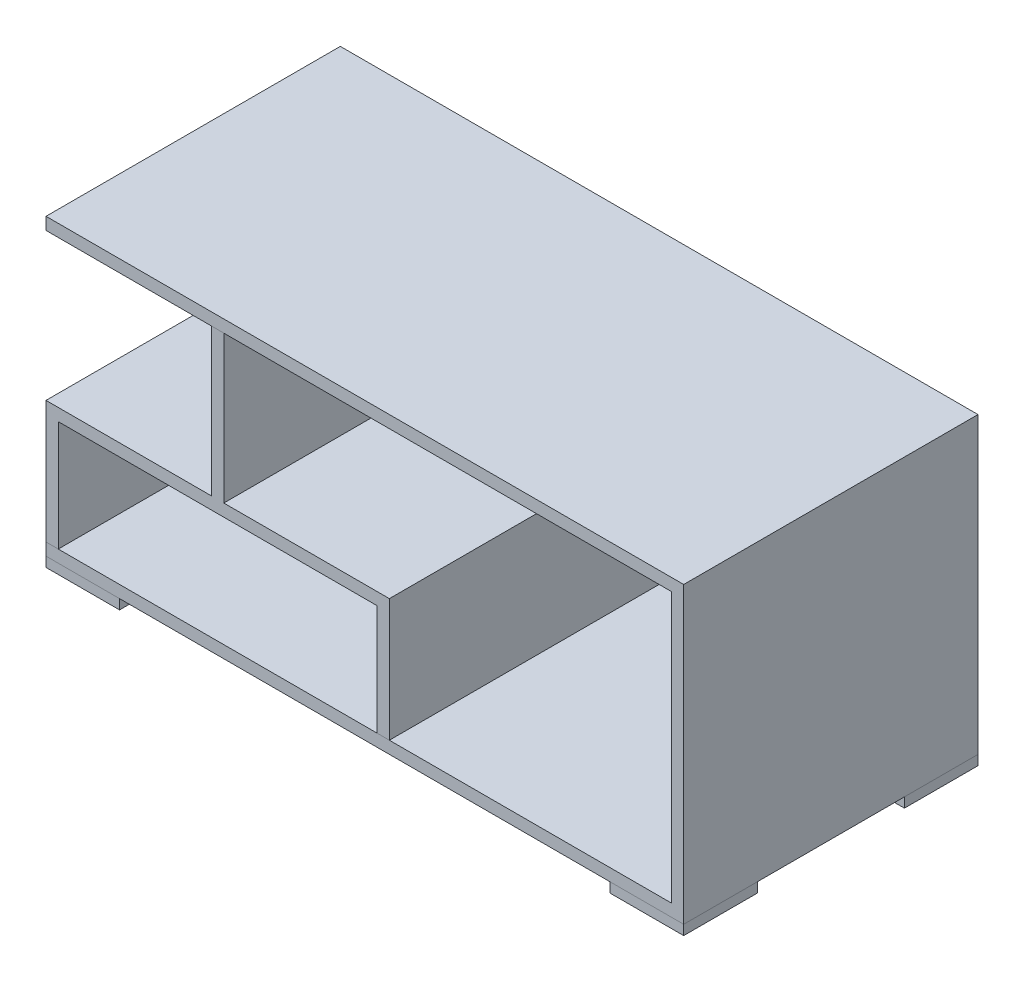
from build123d import *

# Parameters (mm, degrees)
BOSS_EXTRUDE1_DEPTH   = 300
BOSS_EXTRUDE2_DEPTH   = 600
SKETCH3_W             = 150
SKETCH3_H             = 150
BOSS_EXTRUDE3_DEPTH   = 20
BOSS_EXTRUDE3_2_DEPTH = 20
BOSS_EXTRUDE3_3_DEPTH = 20
BOSS_EXTRUDE3_4_DEPTH = 20


with BuildPart() as part:
    # Sketch1 → Boss-Extrude1 (new body, symmetric)
    with BuildSketch(Plane.XY):
        Polygon((-650, 0), (650, 0), (650, 600), (-650, 600), (-650, 575), (625, 575), (625, 25), (-650, 25), align=None)
    extrude(amount=BOSS_EXTRUDE1_DEPTH, both=True)


with BuildPart() as body_2:
    # Sketch2 → Boss-Extrude2 (new body)
    with BuildSketch(Plane.XY.offset(300)):
        Polygon((-312.5, 575), (-312.5, 275), (-650, 275), (-650, 25), (-625, 25), (-625, 250), (25, 250), (25, 25), (50, 25), (50, 275), (-287.5, 275), (-287.5, 575), align=None)
    extrude(amount=-BOSS_EXTRUDE2_DEPTH)


with BuildPart() as body_3:
    # Sketch3 → Boss-Extrude3 (new body)
    with BuildSketch(Plane.XZ):
        with Locations((-575, 225)):
            Rectangle(SKETCH3_W, SKETCH3_H)
    extrude(amount=BOSS_EXTRUDE3_DEPTH)


with BuildPart() as body_4:
    # Sketch3 → Boss-Extrude3 2 (new body)
    with BuildSketch(Plane.XZ):
        with Locations((-575, -225)):
            Rectangle(SKETCH3_W, SKETCH3_H)
    extrude(amount=BOSS_EXTRUDE3_2_DEPTH)


with BuildPart() as body_5:
    # Sketch3 → Boss-Extrude3 3 (new body)
    with BuildSketch(Plane.XZ):
        with Locations((575, 225)):
            Rectangle(SKETCH3_W, SKETCH3_H)
    extrude(amount=BOSS_EXTRUDE3_3_DEPTH)


with BuildPart() as body_6:
    # Sketch3 → Boss-Extrude3 4 (new body)
    with BuildSketch(Plane.XZ):
        with Locations((575, -225)):
            Rectangle(SKETCH3_W, SKETCH3_H)
    extrude(amount=BOSS_EXTRUDE3_4_DEPTH)


solid = Compound([part.part, body_2.part, body_3.part, body_4.part, body_5.part, body_6.part])
